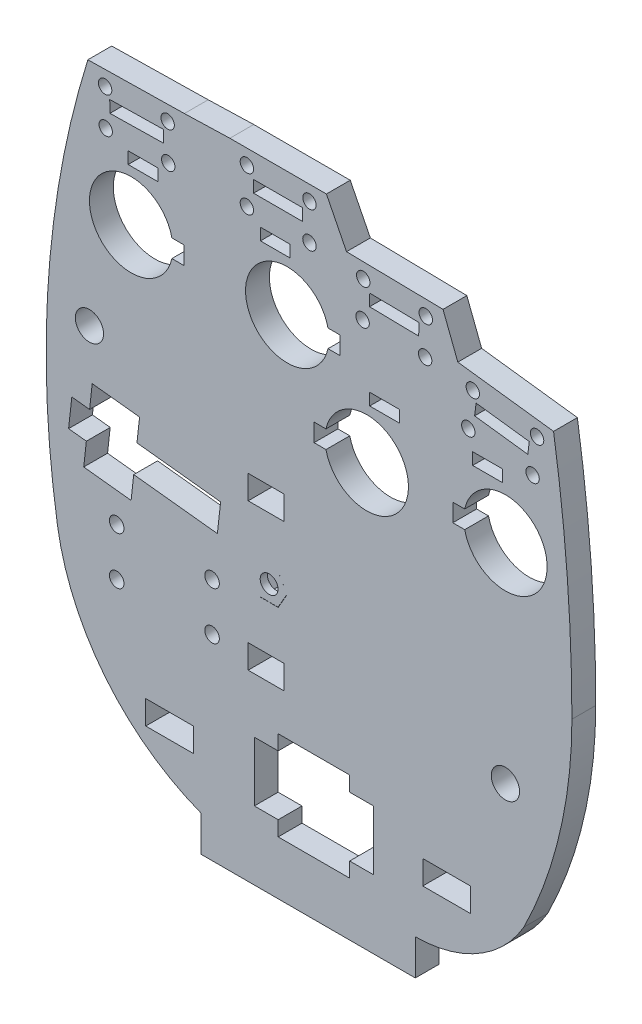
from build123d import *

# Parameters (mm, degrees)
SKETCH1_R           = 2.375
SKETCH1_R_2         = 1.225
SKETCH1_R_3         = 1.125
SKETCH1_W           = 8.25
SKETCH1_H           = 2
SKETCH1_W_2         = 5
SKETCH1_W_3         = 6.000000352
SKETCH1_H_2         = 4
BOSS_EXTRUDE1_DEPTH = 4
SKETCH3_W           = 8
SKETCH3_H           = 4
CUT_EXTRUDE2_DEPTH  = 5
SKETCH4_R           = 2.1
CUT_EXTRUDE3_DEPTH  = 2
SKETCH5_R           = 1.5
BOSS_EXTRUDE2_DEPTH = 1.2


with BuildPart() as part:
    # Sketch1 → Boss-Extrude1 (new body)
    with BuildSketch(Plane.XY):
        with BuildLine():
            Line((-12.978641063, -17.999999648), (-12.978641063, -24))
            Line((-12.978641063, -24), (23.021361236, -24))
            Line((23.021361236, -24), (23.021361236, -17.999999648))
            ThreePointArc((23.021361236, -17.999999648), (33.533081461, -15.187018076), (41.234956591, -7.5))
            ThreePointArc((41.234956591, -7.5), (47.261249953, 9.161168651), (49.306345049, 26.760269155))
            ThreePointArc((49.306345049, 26.760269155), (48.53517536, 46.971383776), (46.226150624, 67.064971353))
            Line((46.226150624, 67.064971353), (30.153849376, 69.095028647))
            Line((30.153849376, 69.095028647), (27.668766331, 75.523635508))
            Line((27.668766331, 75.523635508), (11.471233669, 75.806364492))
            Line((11.471233669, 75.806364492), (8.1, 82.51))
            Line((8.1, 82.51), (-8.1, 82.51))
            Line((-8.1, 82.51), (-15.746235706, 82.281481113))
            Line((-15.746235706, 82.281481113), (-31.943764294, 81.998518887))
            ThreePointArc((-31.943764294, 81.998518887), (-38.536008, 47.204020641), (-37.052658257, 11.821617405))
            ThreePointArc((-37.052658257, 11.821617405), (-29.003702847, -6.308616172), (-12.978641063, -17.999999648))
        make_face()
        with Locations((38.147341743, 11.821617405)):
            Circle(SKETCH1_R, mode=Mode.SUBTRACT)
        with Locations((-27.1, 8.875641236)):
            Circle(SKETCH1_R_2, mode=Mode.SUBTRACT)
        with Locations((-27.1, 16.875641236)):
            Circle(SKETCH1_R_2, mode=Mode.SUBTRACT)
        with Locations((-11.1, 8.875641236)):
            Circle(SKETCH1_R_2, mode=Mode.SUBTRACT)
        with Locations((-11.1, 16.875641236)):
            Circle(SKETCH1_R_2, mode=Mode.SUBTRACT)
        with Locations((-5.25, 80.01)):
            Circle(SKETCH1_R_3, mode=Mode.SUBTRACT)
        with Locations((32.668103408, 66.257595536)):
            Circle(SKETCH1_R_3, mode=Mode.SUBTRACT)
        with Locations((-31.681501662, 43.456405989)):
            Circle(SKETCH1_R, mode=Mode.SUBTRACT)
        with Locations((5.25, 80.01)):
            Circle(SKETCH1_R_3, mode=Mode.SUBTRACT)
        with Locations((5.25, 74.01)):
            Circle(SKETCH1_R_3, mode=Mode.SUBTRACT)
        with Locations((-5.25, 74.01)):
            Circle(SKETCH1_R_3, mode=Mode.SUBTRACT)
        with Locations((-29.050567347, 79.548639007)):
            Circle(SKETCH1_R_3, mode=Mode.SUBTRACT)
        with Locations((-18.552097199, 79.732041708)):
            Circle(SKETCH1_R_3, mode=Mode.SUBTRACT)
        with Locations((-28.945766522, 73.549554345)):
            Circle(SKETCH1_R_3, mode=Mode.SUBTRACT)
        with Locations((-18.447296374, 73.732957046)):
            Circle(SKETCH1_R_3, mode=Mode.SUBTRACT)
        with Locations((24.670854945, 67.074669457)):
            Circle(SKETCH1_R_3, mode=Mode.SUBTRACT)
        with Locations((14.172454146, 67.257919725)):
            Circle(SKETCH1_R_3, mode=Mode.SUBTRACT)
        with Locations((24.775569383, 73.073755628)):
            Circle(SKETCH1_R_3, mode=Mode.SUBTRACT)
        with Locations((14.277168584, 73.257005896)):
            Circle(SKETCH1_R_3, mode=Mode.SUBTRACT)
        with Locations((31.916230336, 60.30489137)):
            Circle(SKETCH1_R_3, mode=Mode.SUBTRACT)
        with Locations((43.457736871, 64.89478048)):
            Circle(SKETCH1_R_3, mode=Mode.SUBTRACT)
        with Locations((42.705863799, 58.942076315)):
            Circle(SKETCH1_R_3, mode=Mode.SUBTRACT)
        with Locations((0, 77.51)):
            Rectangle(SKETCH1_W, SKETCH1_H, mode=Mode.SUBTRACT)
        Polygon((-10.203, 23.9877015), (-9.6615, 28.865490815), (-23.703732608, 30.424366869), (-23.262390208, 34.399944423), (-31.213545315, 35.282629224), (-31.654887716, 31.30705167), (-34.636570881, 31.63805847), (-35.178070881, 26.760269155), (-32.196387716, 26.429262355), (-32.637730116, 22.453684801), (-24.686575009, 21.571), (-24.245232608, 25.546577554), align=None, mode=Mode.SUBTRACT)
        with BuildLine():
            Line((10.358817838, 63.151218734), (10.358817838, 60.151218734))
            Line((10.358817838, 60.151218734), (8.358817838, 60.151218734))
            ThreePointArc((8.358817838, 60.151218734), (-5.478579327, 61.651218734), (8.358817838, 63.151218734))
            Line((8.358817838, 63.151218734), (10.358817838, 63.151218734))
        make_face(mode=Mode.SUBTRACT)
        with Locations((35.147341743, 56.321617405)):
            Rectangle(SKETCH1_W_2, SKETCH1_H, mode=Mode.SUBTRACT)
        with BuildLine():
            Line((-17.84156291, 63.151218734), (-15.84156291, 63.151218734))
            Line((-15.84156291, 63.151218734), (-15.84156291, 60.151218734))
            Line((-15.84156291, 60.151218734), (-17.84156291, 60.151218734))
            ThreePointArc((-17.84156291, 60.151218734), (-31.678960076, 61.651218734), (-17.84156291, 63.151218734))
        make_face(mode=Mode.SUBTRACT)
        Polygon((-28.274482275, 78.062008978), (-19.275783292, 78.219211472), (-19.240849684, 76.219516585), (-28.239548667, 76.06231409), align=None, mode=Mode.SUBTRACT)
        with Locations((17.86306514, 56.321617405)):
            Rectangle(SKETCH1_W_2, SKETCH1_H, mode=Mode.SUBTRACT)
        with Locations((-0.478579327, 71.151218734)):
            Rectangle(SKETCH1_W_2, SKETCH1_H, mode=Mode.SUBTRACT)
        Polygon((15.375818632, 71.737600396), (15.340913819, 69.737905006), (23.589657304, 69.593922653), (23.624562117, 71.593618043), align=None, mode=Mode.SUBTRACT)
        with BuildLine():
            Line((8.025667975, 48.321617405), (6.025667975, 48.321617405))
            Line((6.025667975, 48.321617405), (6.025667975, 45.321617405))
            Line((6.025667975, 45.321617405), (8.025667975, 45.321617405))
            ThreePointArc((8.025667975, 45.321617405), (21.86306514, 46.821617405), (8.025667975, 48.321617405))
        make_face(mode=Mode.SUBTRACT)
        Polygon((42.153636572, 63.54758064), (33.223865999, 64.675480473), (32.973241642, 62.691245751), (41.903012214, 61.563345918), align=None, mode=Mode.SUBTRACT)
        with BuildLine():
            Line((29.309944577, 45.321617405), (31.309944577, 45.321617405))
            ThreePointArc((31.309944577, 45.321617405), (45.147341743, 46.821617405), (31.309944577, 48.321617405))
            Line((31.309944577, 48.321617405), (29.309944577, 48.321617405))
            Line((29.309944577, 48.321617405), (29.309944577, 45.321617405))
        make_face(mode=Mode.SUBTRACT)
        with Locations((-22.678960076, 71.151218734)):
            Rectangle(SKETCH1_W_2, SKETCH1_H, mode=Mode.SUBTRACT)
        Polygon((-4, -2.5), (0, -2.5), (0, 0), (12, 0), (12, -2.5), (16, -2.5), (16, -12.5), (12, -12.5), (12, -15), (0, -15), (0, -12.5), (-4, -12.5), align=None, mode=Mode.SUBTRACT)
        Polygon((0, 23.56093555), (-3, 23.56093555), (-4.5, 20.962859339), (-3, 18.364783128), (0, 18.364783128), (1.5, 20.962859339), align=None, mode=Mode.SUBTRACT)
        with Locations((-2.036620161, 8.717005814)):
            Rectangle(SKETCH1_W_3, SKETCH1_H_2, mode=Mode.SUBTRACT)
        with Locations((-2.036620161, 33.335566927)):
            Rectangle(SKETCH1_W_3, SKETCH1_H_2, mode=Mode.SUBTRACT)
    extrude(amount=BOSS_EXTRUDE1_DEPTH)

    # Sketch3 → Cut-Extrude2 (cut, through all)
    with BuildSketch(Plane(origin=(0, 0, 0), x_dir=(-1, 0, 0), z_dir=(0, 0, -1))):
        with Locations((-28.271360086, -8)):
            Rectangle(SKETCH3_W, SKETCH3_H)
        with Locations((18.228639914, -8)):
            Rectangle(SKETCH3_W, SKETCH3_H)
    extrude(amount=-CUT_EXTRUDE2_DEPTH, mode=Mode.SUBTRACT)

    # Sketch4 → Cut-Extrude3 (cut)
    with BuildSketch(Plane(origin=(0, 0, 0), x_dir=(-1, 0, 0), z_dir=(0, 0, -1))):
        with Locations((27.1, 16.875641236)):
            Circle(SKETCH4_R)
        with Locations((27.1, 8.875641236)):
            Circle(SKETCH4_R)
        with Locations((11.1, 8.875641236)):
            Circle(SKETCH4_R)
        with Locations((11.1, 16.875641236)):
            Circle(SKETCH4_R)
    extrude(amount=-CUT_EXTRUDE3_DEPTH, mode=Mode.SUBTRACT)

    # Sketch5 → Boss-Extrude2 (add)
    with BuildSketch(Plane.XY.offset(4)):
        Polygon((-3.018844903, 18.391695962), (-0.018844903, 18.391695962), (1.481155097, 20.989772174), (-0.018844903, 23.587848385), (-3.018844903, 23.587848385), (-4.518844903, 20.989772174), align=None)
        with Locations((-1.518844903, 20.989772174)):
            Circle(SKETCH5_R, mode=Mode.SUBTRACT)
    extrude(amount=-BOSS_EXTRUDE2_DEPTH)


solid = part.part
